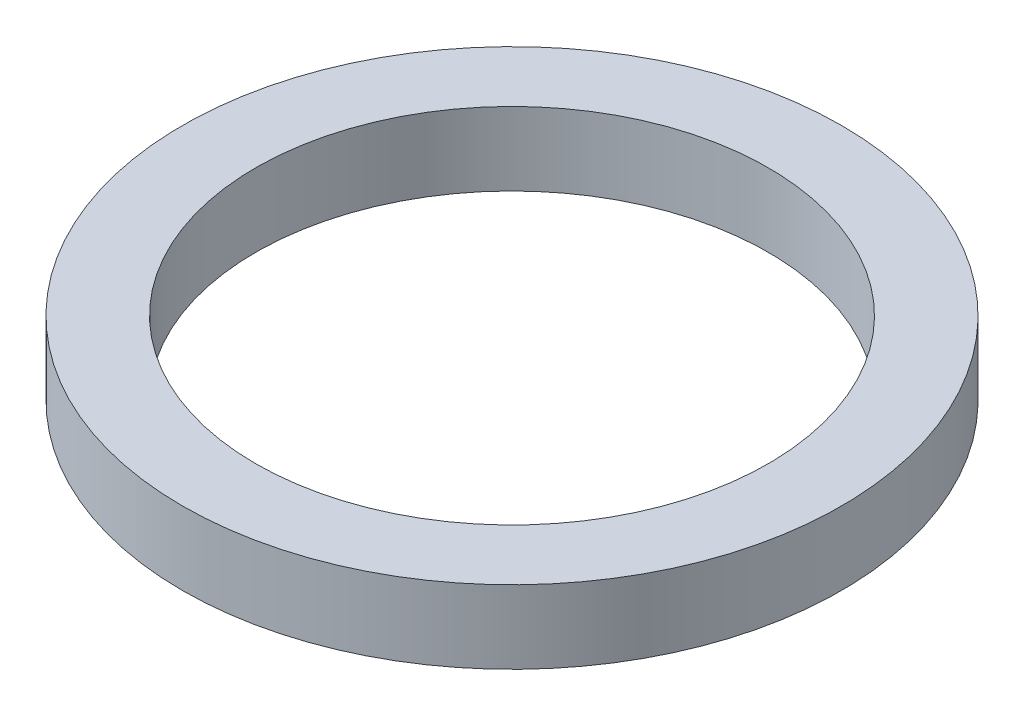
from build123d import *

# Parameters (mm, degrees)
SKETCH1_R           = 45
SKETCH1_R_2         = 35
BOSS_EXTRUDE1_DEPTH = 10


with BuildPart() as part:
    # Sketch1 → Boss-Extrude1 (new body)
    with BuildSketch(Plane(origin=(0, 0, 0), x_dir=(1, 0, 0), z_dir=(0, 1, 0))):
        Circle(SKETCH1_R)
        Circle(SKETCH1_R_2, mode=Mode.SUBTRACT)
    extrude(amount=BOSS_EXTRUDE1_DEPTH)


solid = part.part
